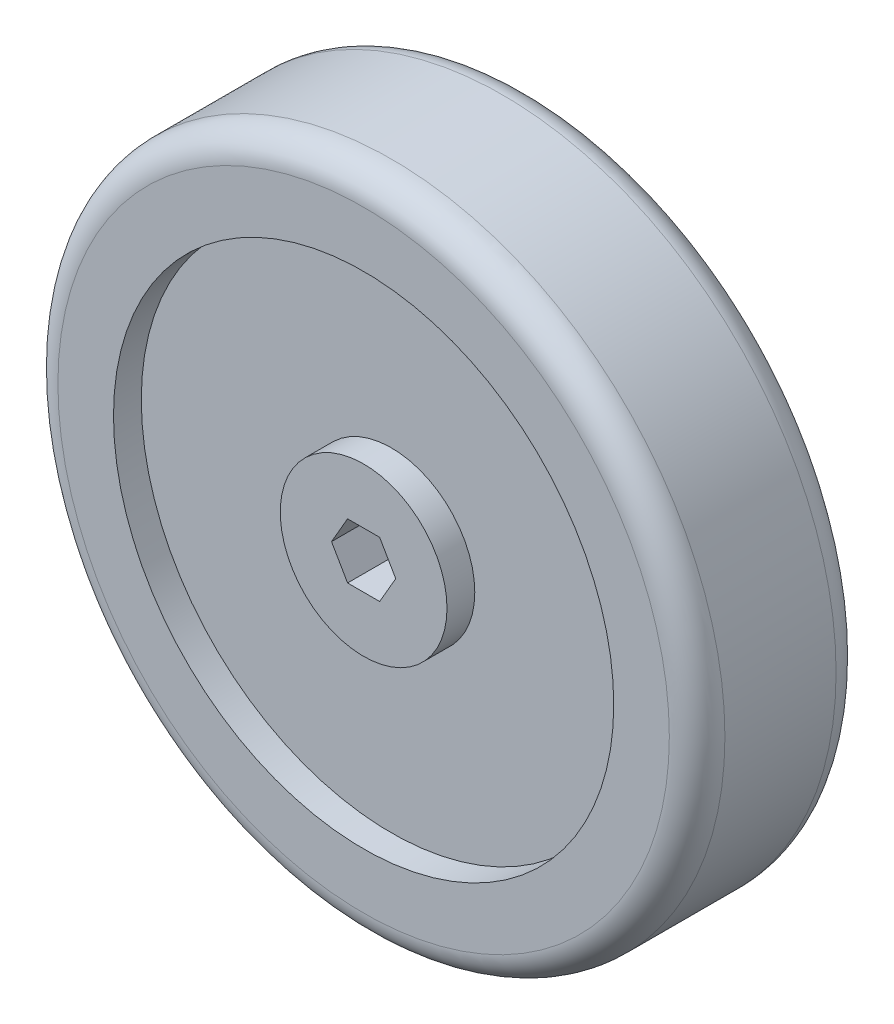
from build123d import *

# Parameters (mm, degrees)
SKETCH1_R           = 76.2
BOSS_EXTRUDE1_DEPTH = 38.1
FILLET1_R           = 6.35
CUT_EXTRUDE2_DEPTH  = 39.1
SKETCH3_R           = 57.15
SKETCH3_R_2         = 19.05
CUT_EXTRUDE3_DEPTH  = 6.35


with BuildPart() as part:
    # Sketch1 → Boss-Extrude1 (new body)
    with BuildSketch(Plane.XY):
        Circle(SKETCH1_R)
    extrude(amount=BOSS_EXTRUDE1_DEPTH)

    # Fillet1
    fillet1_edges = [part.edges().sort_by_distance(p)[0] for p in [
        (-76.2, 0, 0),
        (-76.2, 0, 38.1),
    ]]
    fillet(fillet1_edges, radius=FILLET1_R)

    # Sketch2 → Cut-Extrude2 (cut, through all)
    with BuildSketch(Plane.XY.offset(38.1)):
        Polygon((7.332348419, 0), (3.666174209, 6.35), (-3.666174209, 6.35), (-7.332348419, 0), (-3.666174209, -6.35), (3.666174209, -6.35), align=None)
    extrude(amount=-CUT_EXTRUDE2_DEPTH, mode=Mode.SUBTRACT)

    # Sketch3 → Cut-Extrude3 (cut)
    with BuildSketch(Plane.XY.offset(38.1)):
        Circle(SKETCH3_R)
        Circle(SKETCH3_R_2, mode=Mode.SUBTRACT)
    cut_extrude3 = extrude(amount=-CUT_EXTRUDE3_DEPTH, mode=Mode.SUBTRACT)

    # Mirror1: Cut-Extrude3 across plane
    add(cut_extrude3.mirror(Plane.XY.offset(19.05)), mode=Mode.SUBTRACT)


solid = part.part
